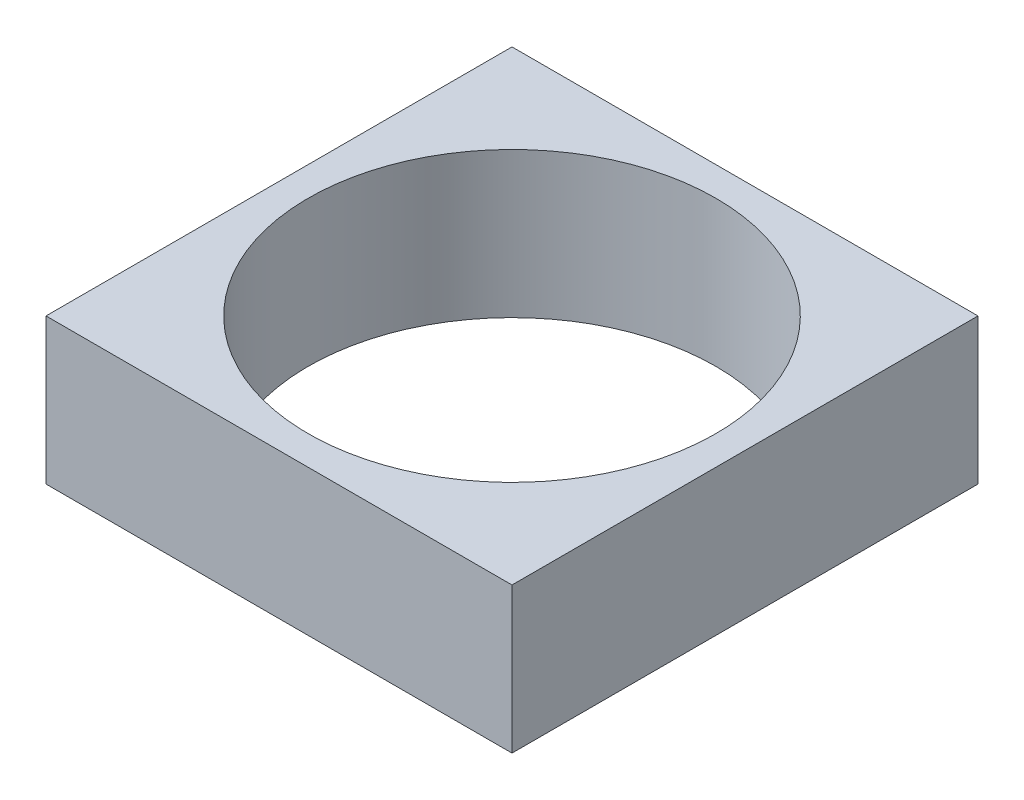
from build123d import *

# Parameters (mm, degrees)
SKETCH1_W           = 80
SKETCH1_H           = 80
BOSS_EXTRUDE1_DEPTH = 25
SKETCH2_R           = 35
CUT_EXTRUDE1_DEPTH  = 26


with BuildPart() as part:
    # Sketch1 → Boss-Extrude1 (new body)
    with BuildSketch(Plane(origin=(0, 0, 0), x_dir=(1, 0, 0), z_dir=(0, 1, 0))):
        Rectangle(SKETCH1_W, SKETCH1_H)
    extrude(amount=BOSS_EXTRUDE1_DEPTH)

    # Sketch2 → Cut-Extrude1 (cut, through all)
    with BuildSketch(Plane.XZ):
        Circle(SKETCH2_R)
    extrude(amount=-CUT_EXTRUDE1_DEPTH, mode=Mode.SUBTRACT)


solid = part.part
